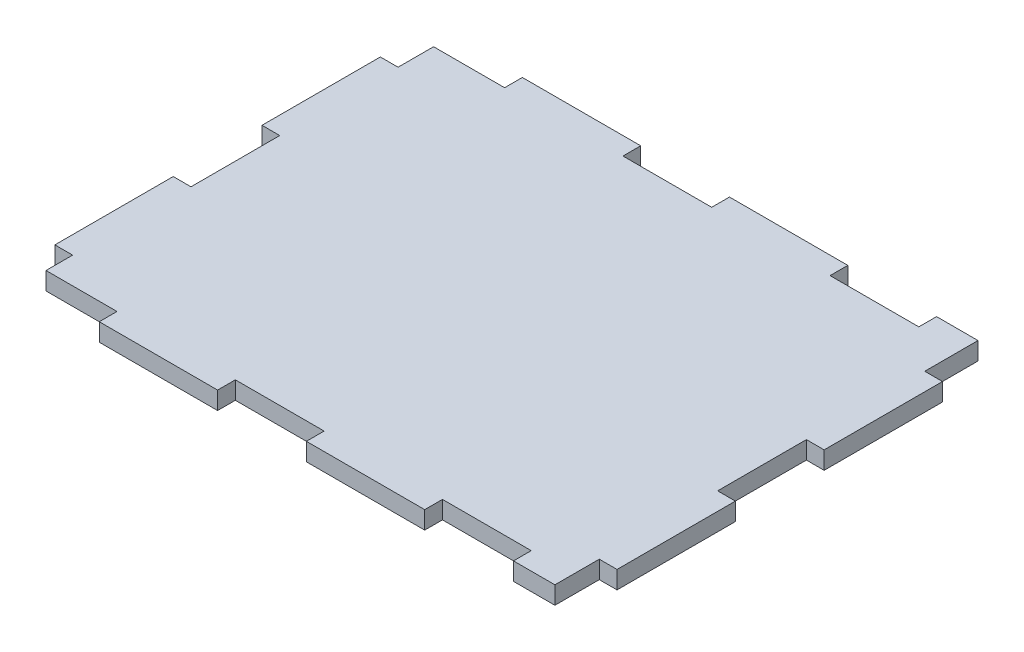
from build123d import *

# Parameters (mm, degrees)
BOSS_EXTRUDE1_DEPTH = 3


with BuildPart() as part:
    # Sketch1 → Boss-Extrude1 (new body)
    with BuildSketch(Plane(origin=(0, 0, 0), x_dir=(1, 0, 0), z_dir=(0, 1, 0))):
        Polygon((12, 65.5), (0, 65.5), (0, 59.5), (-3, 59.5), (-3, 39.5), (0, 39.5), (0, 24.5), (-3, 24.5), (-3, 4.5), (0, 4.5), (0, 0), (12, 0), (12, -3), (32, -3), (32, 0), (47, 0), (47, -3), (67, -3), (67, 0), (82, 0), (82, -3), (89, -3), (89, 0), (89, 4.5), (92, 4.5), (92, 24.5), (89, 24.5), (89, 39.5), (92, 39.5), (92, 59.5), (89, 59.5), (89, 65.5), (89, 68.5), (82, 68.5), (82, 65.5), (67, 65.5), (67, 68.5), (47, 68.5), (47, 65.5), (32, 65.5), (32, 68.5), (12, 68.5), align=None)
    extrude(amount=BOSS_EXTRUDE1_DEPTH)


solid = part.part
